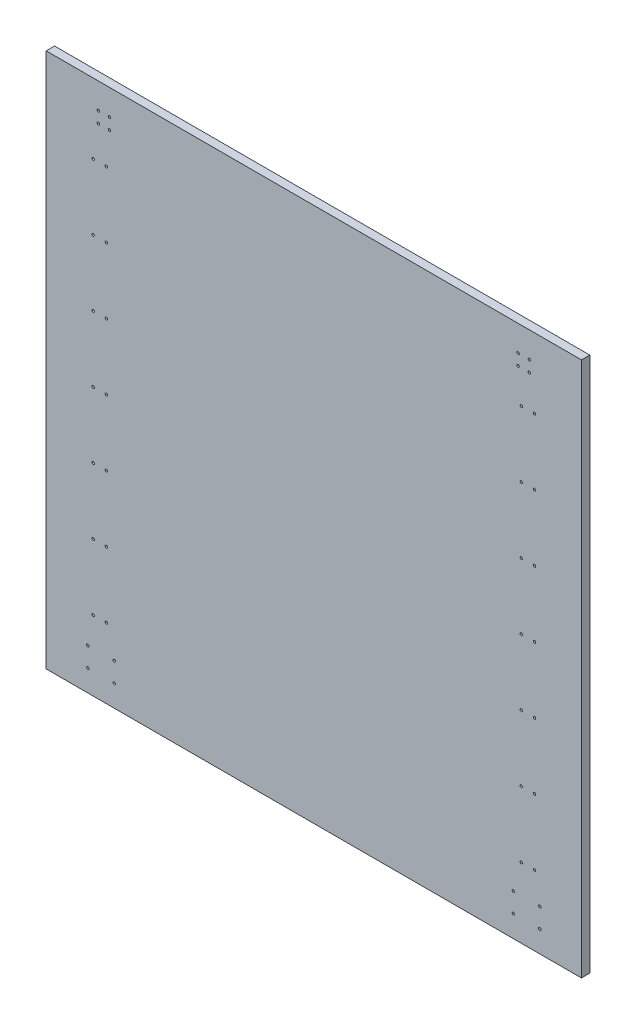
from build123d import *

# Parameters (mm, degrees)
SKETCH1_W                                       = 1219.2
SKETCH1_H                                       = 1219.2
BOSS_EXTRUDE1_DEPTH                             = 19.05
CSK_FOR_M5_FLAT_HEAD_MACHINE_SCREW1_D           = 5.5
CSK_FOR_M5_FLAT_HEAD_MACHINE_SCREW1_CSINK_D     = 10.4
CSK_FOR_M5_FLAT_HEAD_MACHINE_SCREW1_CSINK_ANGLE = 90


with BuildPart() as part:
    # Sketch1 → Boss-Extrude1 (new body)
    with BuildSketch(Plane.XY):
        Rectangle(SKETCH1_W, SKETCH1_H)
    extrude(amount=BOSS_EXTRUDE1_DEPTH)

    # CSK for M5 Flat Head Machine Screw1 (through all)
    with Locations(Plane(origin=(0, 0, 0), x_dir=(-1, 0, 0), z_dir=(0, 0, -1))):
        with Locations((-514.725, -515.875), (-514.725, -560.325), (-454.4, -560.325), (-454.4, -515.875), (-502.5625, -450), (-472.5625, -450), (-502.5625, -300), (-472.5625, -300), (-502.5625, -150), (-472.5625, -150), (-502.5625, 0), (-472.5625, 0), (-502.5625, 150), (-472.5625, 150), (-502.5625, 300), (-472.5625, 300), (-502.5625, 450), (-472.5625, 450), (-490.7625, 525.4), (-490.7625, 550.8), (-465.3625, 550.8), (-465.3625, 525.4), (465.3625, 525.4), (472.5625, 150), (502.5625, 150), (472.5625, 300), (502.5625, 300), (472.5625, 450), (502.5625, 450), (490.7625, 525.4), (490.7625, 550.8), (465.3625, 550.8), (454.4, -515.875), (454.4, -560.325), (514.725, -560.325), (514.725, -515.875), (472.5625, -450), (502.5625, -450), (472.5625, -300), (502.5625, -300), (472.5625, -150), (502.5625, -150), (472.5625, 0), (502.5625, 0)):
            CounterSinkHole(CSK_FOR_M5_FLAT_HEAD_MACHINE_SCREW1_D / 2, CSK_FOR_M5_FLAT_HEAD_MACHINE_SCREW1_CSINK_D / 2, counter_sink_angle=CSK_FOR_M5_FLAT_HEAD_MACHINE_SCREW1_CSINK_ANGLE)


solid = part.part
